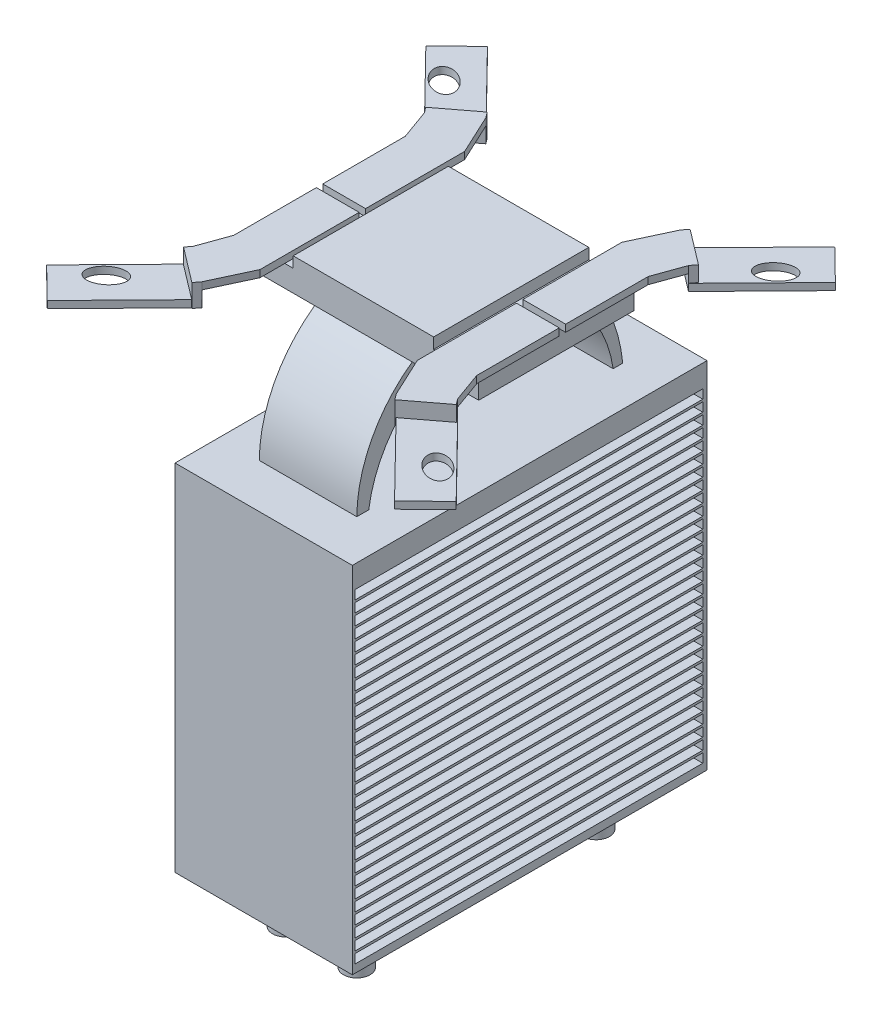
from build123d import *

# Parameters (mm, degrees)
SKETCH1_W                = 40
SKETCH1_H                = 80
BOSS_EXTRUDE1_DEPTH      = 80
SKETCH2_R                = 3
BOSS_EXTRUDE2_DEPTH      = 11
SKETCH7_W                = 22
SKETCH7_H                = 60
BOSS_EXTRUDE4_DEPTH      = 24
SKETCH8_W                = 52
SKETCH8_H                = 35
BOSS_EXTRUDE5_DEPTH      = 4.86
SKETCH9_W                = 31.68
SKETCH9_H                = 35
BOSS_EXTRUDE6_DEPTH      = 2.4384
BOSS_EXTRUDE9_DEPTH      = 1.6002
SKETCH13_W               = 9.894024857
SKETCH13_H               = 5.08
BOSS_EXTRUDE10_DEPTH     = 1.6002
SKETCH12_W               = 78.488418751
SKETCH12_H               = 2.032
CUT_EXTRUDE1_DEPTH       = 129.626313386
SKETCH15_RX              = 3.8961283
SKETCH15_RY              = 2.54
BOSS_EXTRUDE11_DEPTH     = 1.6002
MIRROR2_COPY_1_SKETCH_W  = 9.894024857
MIRROR2_COPY_1_SKETCH_H  = 5.08
MIRROR2_COPY_1_DEPTH     = 1.6002
MIRROR2_COPY_2_SKETCH_RX = 3.8961283
MIRROR2_COPY_2_SKETCH_RY = 2.54
MIRROR2_COPY_2_DEPTH     = 1.6002
MIRROR2_COPY_3_SKETCH_W  = 9.894024857
MIRROR2_COPY_3_SKETCH_H  = 5.08
MIRROR2_COPY_3_DEPTH     = 1.6002
MIRROR2_COPY_4_SKETCH_RX = 3.8961283
MIRROR2_COPY_4_SKETCH_RY = 2.54
MIRROR2_COPY_4_DEPTH     = 1.6002
CUT_EXTRUDE15_DEPTH      = 25.4
CUT_EXTRUDE16_DEPTH      = 25.4
CUT_EXTRUDE17_DEPTH      = 25.4


with BuildPart() as part:
    # Sketch1 → Boss-Extrude1 (new body)
    with BuildSketch(Plane(origin=(0, 0, 0), x_dir=(1, 0, 0), z_dir=(0, 1, 0))):
        with Locations((-32.127066409, -0.947148945)):
            Rectangle(SKETCH1_W, SKETCH1_H)
    extrude(amount=BOSS_EXTRUDE1_DEPTH)

    # Sketch2 → Boss-Extrude2 (add)
    with BuildSketch(Plane.XZ):
        with Locations((-40.127066409, 27.947148945)):
            Circle(SKETCH2_R)
        with Locations((-40.127066409, -26.052851055)):
            Circle(SKETCH2_R)
        with Locations((-24.127066409, 27.947148945)):
            Circle(SKETCH2_R)
        with Locations((-24.127066409, -26.052851055)):
            Circle(SKETCH2_R)
    extrude(amount=BOSS_EXTRUDE2_DEPTH)

    # Sketch7 → Boss-Extrude4 (add)
    with BuildSketch(Plane(origin=(0, 80, 0), x_dir=(1, 0, 0), z_dir=(0, 1, 0))):
        with Locations((-32.127066409, -0.947148945)):
            Rectangle(SKETCH7_W, SKETCH7_H)
    extrude(amount=BOSS_EXTRUDE4_DEPTH)

    # Sketch8 → Boss-Extrude5 (add)
    with BuildSketch(Plane(origin=(0, 104, 0), x_dir=(1, 0, 0), z_dir=(0, 1, 0))):
        with Locations((-32.127066409, -0.947148945)):
            Rectangle(SKETCH8_W, SKETCH8_H)
    extrude(amount=BOSS_EXTRUDE5_DEPTH)

    # Sketch9 → Boss-Extrude6 (add)
    with BuildSketch(Plane(origin=(0, 108.86, 0), x_dir=(1, 0, 0), z_dir=(0, 1, 0))):
        with Locations((-32.127066409, -0.947148945)):
            Rectangle(SKETCH9_W, SKETCH9_H)
    extrude(amount=BOSS_EXTRUDE6_DEPTH)

    # Sketch10 → Boss-Extrude9 (add)
    with BuildSketch(Plane(origin=(0, 108.86, 0), x_dir=(1, 0, 0), z_dir=(0, 1, 0))):
        Polygon((-14.382066409, -1.672148945), (-4.730066409, -1.672148945), (-4.730066409, -20.290348945), (-2.320182887, -26.981612309), (-10.204868605, -32.978325337), (-14.382066409, -24.024148945), align=None)
        Polygon((-14.382066409, -0.222148945), (-4.730066409, -0.222148945), (-4.730066409, 18.396051055), (-2.320182887, 25.08731442), (-10.204868605, 31.084027448), (-14.382066409, 22.129851055), align=None)
        Polygon((-49.872066409, 22.129851055), (-54.049264213, 31.084027448), (-61.93394993, 25.08731442), (-59.524066409, 18.396051055), (-59.524066409, -0.222148945), (-49.872066409, -0.222148945), align=None)
        Polygon((-59.524066409, -20.290348945), (-61.93394993, -26.981612309), (-54.049264213, -32.978325337), (-49.872066409, -24.024148945), (-49.872066409, -1.672148945), (-59.524066409, -1.672148945), align=None)
    extrude(amount=BOSS_EXTRUDE9_DEPTH)

    # Sketch13 → Boss-Extrude10 (add)
    with BuildSketch(Plane(origin=(12.150504172, 0, 15.975903176), x_dir=(0.7959505064969249, 0, -0.6053617027920487), z_dir=(0.6053617027920487, 0, 0.7959505064969249))):
        with Locations((-23.139373088, 107.9202)):
            Rectangle(SKETCH13_W, SKETCH13_H)
    boss_extrude10 = extrude(amount=BOSS_EXTRUDE10_DEPTH)

    # Sketch12 → Cut-Extrude1 (cut, through all)
    with BuildSketch(Plane(origin=(-12.127066409, 0, 0), x_dir=(0, 0, -1), z_dir=(1, 0, 0))):
        with Locations((-1.133364117, 71.409675219)):
            Rectangle(SKETCH12_W, SKETCH12_H)
        with Locations((-1.133364117, 73.949675219)):
            Rectangle(SKETCH12_W, SKETCH12_H)
        with Locations((-1.133364117, 68.869675219)):
            Rectangle(SKETCH12_W, SKETCH12_H)
        with Locations((-1.133364117, 66.329675219)):
            Rectangle(SKETCH12_W, SKETCH12_H)
        with Locations((-1.133364117, 63.789675219)):
            Rectangle(SKETCH12_W, SKETCH12_H)
        with Locations((-1.133364117, 61.249675219)):
            Rectangle(SKETCH12_W, SKETCH12_H)
        with Locations((-1.133364117, 58.709675219)):
            Rectangle(SKETCH12_W, SKETCH12_H)
        with Locations((-1.133364117, 56.169675219)):
            Rectangle(SKETCH12_W, SKETCH12_H)
        with Locations((-1.133364117, 53.629675219)):
            Rectangle(SKETCH12_W, SKETCH12_H)
        with Locations((-1.133364117, 51.089675219)):
            Rectangle(SKETCH12_W, SKETCH12_H)
        with Locations((-1.133364117, 48.549675219)):
            Rectangle(SKETCH12_W, SKETCH12_H)
        with Locations((-1.133364117, 46.009675219)):
            Rectangle(SKETCH12_W, SKETCH12_H)
        with Locations((-1.133364117, 43.469675219)):
            Rectangle(SKETCH12_W, SKETCH12_H)
        with Locations((-1.133364117, 40.929675219)):
            Rectangle(SKETCH12_W, SKETCH12_H)
        with Locations((-1.133364117, 38.389675219)):
            Rectangle(SKETCH12_W, SKETCH12_H)
        with Locations((-1.133364117, 35.849675219)):
            Rectangle(SKETCH12_W, SKETCH12_H)
        with Locations((-1.133364117, 33.309675219)):
            Rectangle(SKETCH12_W, SKETCH12_H)
        with Locations((-1.133364117, 30.769675219)):
            Rectangle(SKETCH12_W, SKETCH12_H)
        with Locations((-1.133364117, 28.229675219)):
            Rectangle(SKETCH12_W, SKETCH12_H)
        with Locations((-1.133364117, 25.689675219)):
            Rectangle(SKETCH12_W, SKETCH12_H)
        with Locations((-1.133364117, 23.149675219)):
            Rectangle(SKETCH12_W, SKETCH12_H)
        with Locations((-1.133364117, 20.609675219)):
            Rectangle(SKETCH12_W, SKETCH12_H)
        with Locations((-1.133364117, 18.069675219)):
            Rectangle(SKETCH12_W, SKETCH12_H)
        with Locations((-1.133364117, 15.529675219)):
            Rectangle(SKETCH12_W, SKETCH12_H)
        with Locations((-1.133364117, 12.989675219)):
            Rectangle(SKETCH12_W, SKETCH12_H)
        with Locations((-1.133364117, 10.449675219)):
            Rectangle(SKETCH12_W, SKETCH12_H)
        with Locations((-1.133364117, 7.909675219)):
            Rectangle(SKETCH12_W, SKETCH12_H)
        with Locations((-1.133364117, 5.369675219)):
            Rectangle(SKETCH12_W, SKETCH12_H)
        with Locations((-1.133364117, 2.829675219)):
            Rectangle(SKETCH12_W, SKETCH12_H)
    extrude(amount=-CUT_EXTRUDE1_DEPTH, mode=Mode.SUBTRACT)

    # Sketch15 → Boss-Extrude11 (add)
    with BuildSketch(Plane.XZ.offset(-105.3802)):
        Polygon((7.044757785, 50.599049206), (14.067302416, 43.721960161), (-2.323693549, 26.98428235), (-10.208379266, 32.980995378), align=None)
        with Locations(Location((5.270922929, 39.049818985), (0, 0, -142.440574459))):
            Ellipse(SKETCH15_RX, SKETCH15_RY, mode=Mode.SUBTRACT)
    boss_extrude11 = extrude(amount=-BOSS_EXTRUDE11_DEPTH)

    # Mirror1: Boss-Extrude10, Boss-Extrude11 across plane
    add(boss_extrude10.mirror(Plane.XY.offset(0.947148945)))
    add(boss_extrude11.mirror(Plane.XY.offset(0.947148945)))

    # Mirror2 copy 1 sketch → Mirror2 copy 1 (add)
    with BuildSketch(Plane(origin=(-76.40463699, 0, -14.081605287), x_dir=(-0.7959505064969249, 0, 0.6053617027920487), z_dir=(-0.6053617027920487, 0, -0.7959505064969249))):
        with Locations((-23.139373088, 107.9202)):
            Rectangle(MIRROR2_COPY_1_SKETCH_W, MIRROR2_COPY_1_SKETCH_H)
    extrude(amount=MIRROR2_COPY_1_DEPTH)

    # Mirror2 copy 2 sketch → Mirror2 copy 2 (add)
    with BuildSketch(Plane(origin=(-64.254132818, 105.3802, 1.894297889), x_dir=(-1, 0, 0), z_dir=(0, -1, 0))):
        Polygon((7.044757785, 50.599049206), (14.067302416, 43.721960161), (-2.323693549, 26.98428235), (-10.208379266, 32.980995378), align=None)
        with Locations(Location((5.270922929, 39.049818985), (0, 0, -142.440574459))):
            Ellipse(MIRROR2_COPY_2_SKETCH_RX, MIRROR2_COPY_2_SKETCH_RY, mode=Mode.SUBTRACT)
    extrude(amount=-MIRROR2_COPY_2_DEPTH)

    # Mirror2 copy 3 sketch → Mirror2 copy 3 (add)
    with BuildSketch(Plane(origin=(-76.40463699, 0, 15.975903176), x_dir=(-0.7959505064969249, 0, -0.6053617027920487), z_dir=(-0.6053617027920487, 0, 0.7959505064969249))):
        with Locations((-23.139373088, -107.9202)):
            Rectangle(MIRROR2_COPY_3_SKETCH_W, MIRROR2_COPY_3_SKETCH_H)
    extrude(amount=MIRROR2_COPY_3_DEPTH)

    # Mirror2 copy 4 sketch → Mirror2 copy 4 (add)
    with BuildSketch(Plane(origin=(-64.254132818, 105.3802, 0), x_dir=(-1, 0, 0), z_dir=(0, -1, 0))):
        Polygon((7.044757785, -50.599049206), (14.067302416, -43.721960161), (-2.323693549, -26.98428235), (-10.208379266, -32.980995378), align=None)
        with Locations(Location((5.270922929, -39.049818985), (0, 0, 142.440574459))):
            Ellipse(MIRROR2_COPY_4_SKETCH_RX, MIRROR2_COPY_4_SKETCH_RY, mode=Mode.SUBTRACT)
    extrude(amount=-MIRROR2_COPY_4_DEPTH)

    # Sketch22 → Cut-Extrude15 (cut)
    with BuildSketch(Plane(origin=(-21.127066409, 0, 0), x_dir=(0, 0, -1), z_dir=(1, 0, 0))):
        with BuildLine():
            Line((-28.24540856, 80), (26.886294025, 80))
            ThreePointArc((26.886294025, 80), (-0.679557267, 103.879474172), (-28.24540856, 80))
        make_face()
    extrude(amount=-CUT_EXTRUDE15_DEPTH, mode=Mode.SUBTRACT)

    # Sketch24 → Cut-Extrude16 (cut)
    with BuildSketch(Plane(origin=(-21.127066409, 0, 0), x_dir=(0, 0, -1), z_dir=(1, 0, 0))):
        with BuildLine():
            Line((-30.947148945, 104), (-18.447148945, 104))
            ThreePointArc((-18.447148945, 104), (-27.574020245, 93.498370469), (-30.947148945, 80))
            Line((-30.947148945, 80), (-30.947148945, 104))
        make_face()
    extrude(amount=-CUT_EXTRUDE16_DEPTH, mode=Mode.SUBTRACT)

    # Sketch25 → Cut-Extrude17 (cut)
    with BuildSketch(Plane(origin=(-21.127066409, 0, 0), x_dir=(0, 0, -1), z_dir=(1, 0, 0))):
        with BuildLine():
            Line((16.552851055, 104), (29.052851055, 104))
            Line((29.052851055, 104), (29.052851055, 80))
            ThreePointArc((29.052851055, 80), (25.125097921, 93.209503576), (16.552851055, 104))
        make_face()
    extrude(amount=-CUT_EXTRUDE17_DEPTH, mode=Mode.SUBTRACT)


solid = part.part
